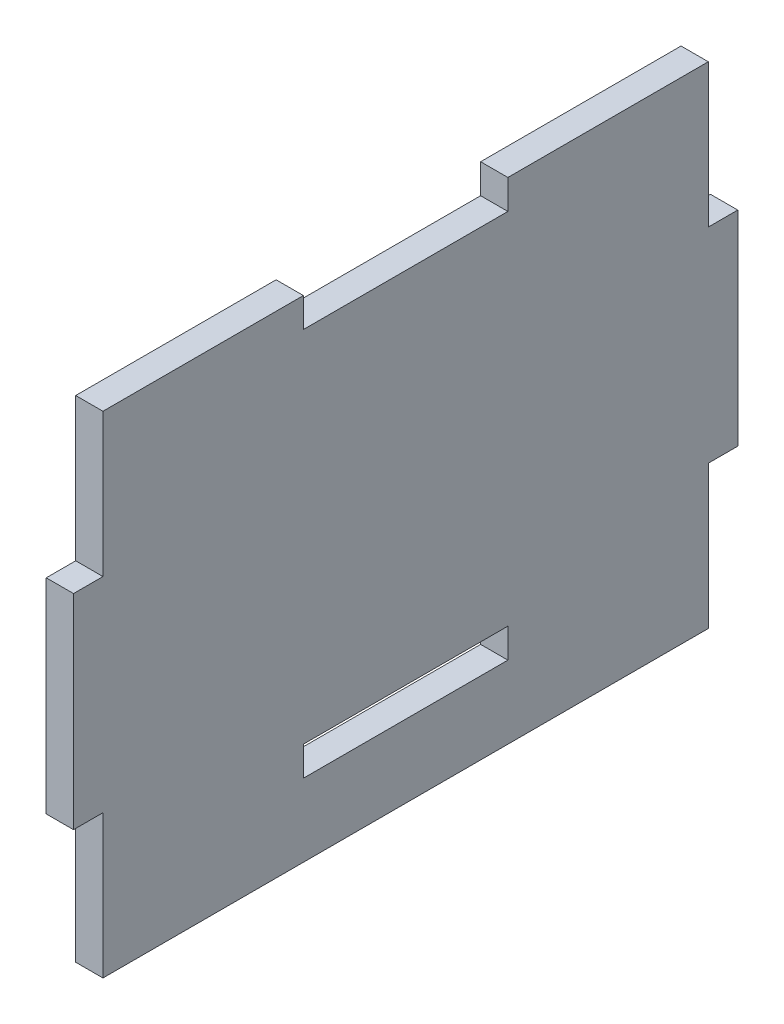
from build123d import *

# Parameters (mm, degrees)
SKETCH1_W           = 56.388
SKETCH1_H           = 45.72
BOSS_EXTRUDE1_DEPTH = 2.54
SKETCH2_W           = 2.7432
SKETCH2_H           = 19.05
BOSS_EXTRUDE2_DEPTH = 2.54
SKETCH3_W           = 19.05
SKETCH3_H           = 2.7432
CUT_EXTRUDE1_DEPTH  = 3.54


with BuildPart() as part:
    # Sketch1 → Boss-Extrude1 (new body)
    with BuildSketch(Plane(origin=(0, 0, 0), x_dir=(0, 0, -1), z_dir=(1, 0, 0))):
        Rectangle(SKETCH1_W, SKETCH1_H)
    extrude(amount=BOSS_EXTRUDE1_DEPTH)

    # Sketch2 → Boss-Extrude2 (add)
    with BuildSketch(Plane(origin=(2.54, 0, 0), x_dir=(0, 0, -1), z_dir=(1, 0, 0))):
        with Locations((-29.5656, 0)):
            Rectangle(SKETCH2_W, SKETCH2_H)
        with Locations((29.5656, 0)):
            Rectangle(SKETCH2_W, SKETCH2_H)
    extrude(amount=-BOSS_EXTRUDE2_DEPTH)

    # Sketch3 → Cut-Extrude1 (cut, through all)
    with BuildSketch(Plane(origin=(2.54, 0, 0), x_dir=(0, 0, -1), z_dir=(1, 0, 0))):
        with Locations((0, 21.4884)):
            Rectangle(SKETCH3_W, SKETCH3_H)
        with Locations((0, -14.7066)):
            Rectangle(SKETCH3_W, SKETCH3_H)
    extrude(amount=-CUT_EXTRUDE1_DEPTH, mode=Mode.SUBTRACT)


solid = part.part
